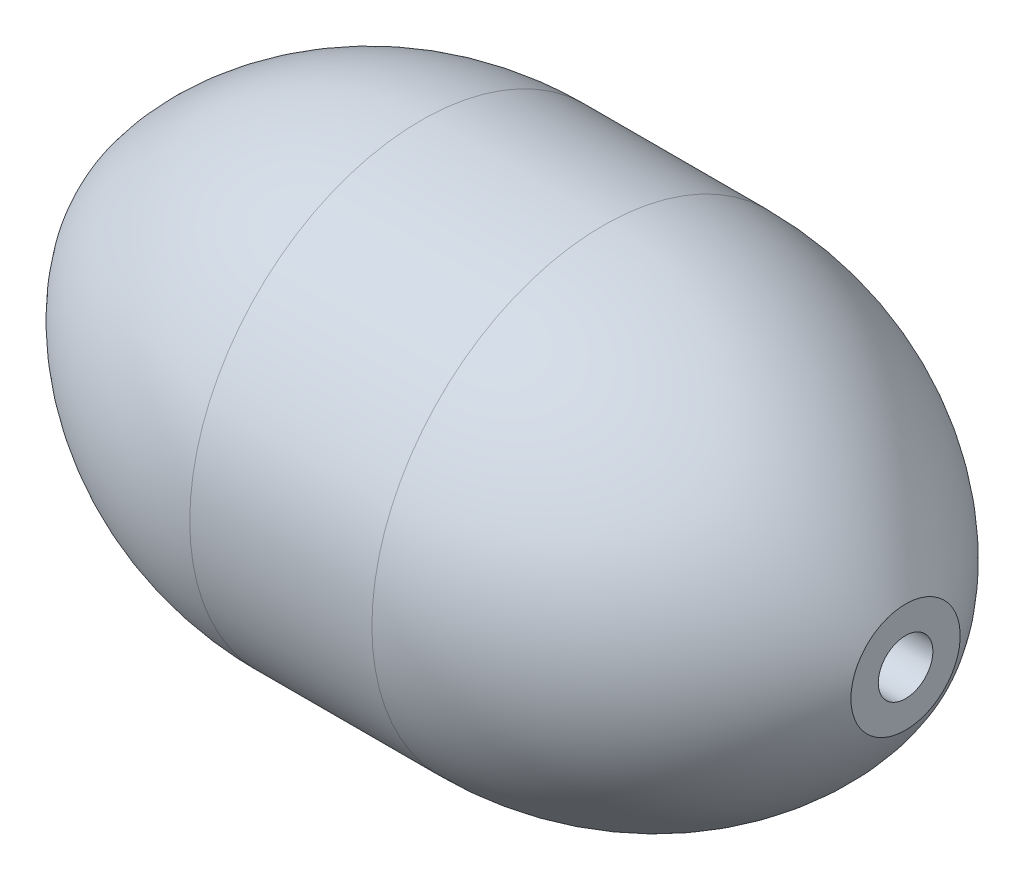
from build123d import *


with BuildPart() as part:
    # Sketch1 → Revolve1 (revolve)
    with BuildSketch(Plane.XY, mode=Mode.PRIVATE) as revolve1_sk:
        with BuildLine():
            Line((-0.5, 1.27), (0.5, 1.27))
            ThreePointArc((0.5, 1.27), (1.461314205, 1.009723278), (2.16, 0.3))
            Line((2.16, 0.3), (2.16, 0.15))
            Line((2.16, 0.15), (-2.16, 0.15))
            Line((-2.16, 0.15), (-2.16, 0.3))
            ThreePointArc((-2.16, 0.3), (-1.461314205, 1.009723278), (-0.5, 1.27))
        make_face()
    revolve(revolve1_sk.sketch.rotate(Axis((-2.16, 0, 0), (1, 0, 0)), 90), axis=Axis((-2.16, 0, 0), (1, 0, 0)))  # turned: the seam where the file's is


solid = part.part
